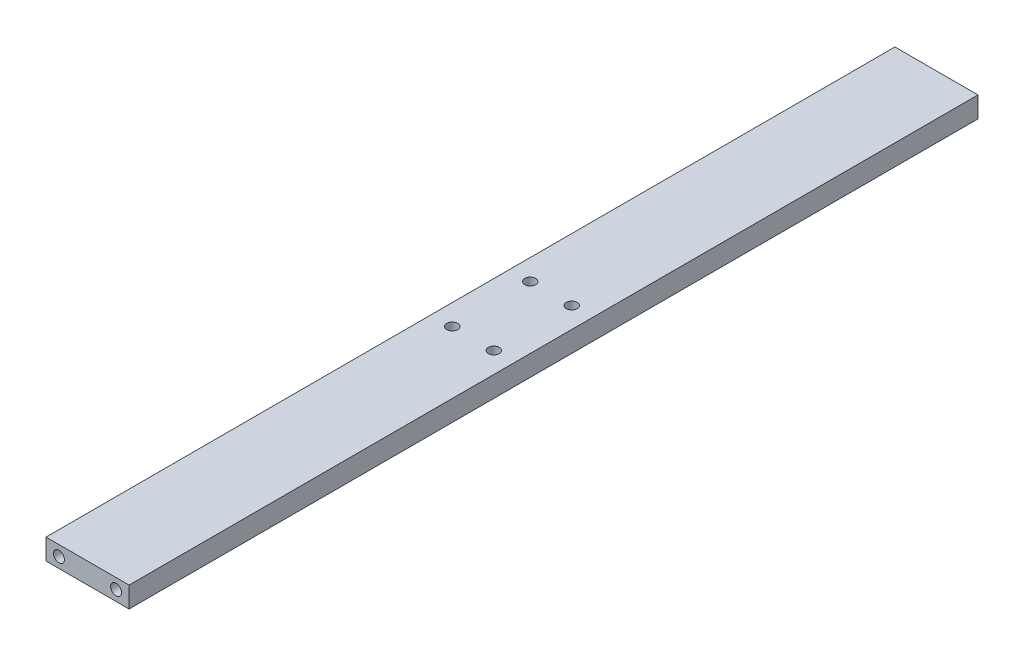
from build123d import *

# Parameters (mm, degrees)
SKETCH1_W           = 32
SKETCH1_H           = 8
BOSS_EXTRUDE1_DEPTH = 163.5
SKETCH2_R           = 2.1
CUT_EXTRUDE1_DEPTH  = 10
CUT_EXTRUDE2_REACH  = 10
SKETCH3_R           = 2.1


with BuildPart() as part:
    # Sketch1 → Boss-Extrude1 (new body, symmetric)
    with BuildSketch(Plane.XY):
        Rectangle(SKETCH1_W, SKETCH1_H)
    extrude(amount=BOSS_EXTRUDE1_DEPTH, both=True)

    # Sketch2 → Cut-Extrude1 (cut)
    with BuildSketch(Plane.XY.offset(163.5)):
        with Locations((11, 0)):
            Circle(SKETCH2_R)
        with Locations((-11, 0)):
            Circle(SKETCH2_R)
    cut_extrude1 = extrude(amount=-CUT_EXTRUDE1_DEPTH, mode=Mode.SUBTRACT)

    # Mirror1: Cut-Extrude1 across plane
    add(cut_extrude1.mirror(Plane.XY), mode=Mode.SUBTRACT)

    # Sketch3 → Cut-Extrude2 (cut, up to next)
    with BuildSketch(Plane(origin=(0, 4, 0), x_dir=(1, 0, 0), z_dir=(0, 1, 0)), mode=Mode.PRIVATE) as cut_extrude2_sk1:
        with Locations((-8, -15)):
            Circle(SKETCH3_R)
    cut_extrude2_tool1 = extrude(cut_extrude2_sk1.sketch, amount=-CUT_EXTRUDE2_REACH, mode=Mode.PRIVATE) & part.part
    add(cut_extrude2_tool1.solids().sort_by_distance((-8, 4, 15))[0], mode=Mode.SUBTRACT)
    # Sketch3 → Cut-Extrude2 (cut, up to next)
    with BuildSketch(Plane(origin=(0, 4, 0), x_dir=(1, 0, 0), z_dir=(0, 1, 0)), mode=Mode.PRIVATE) as cut_extrude2_sk2:
        with Locations((-8, 15)):
            Circle(SKETCH3_R)
    cut_extrude2_tool2 = extrude(cut_extrude2_sk2.sketch, amount=-CUT_EXTRUDE2_REACH, mode=Mode.PRIVATE) & part.part
    add(cut_extrude2_tool2.solids().sort_by_distance((-8, 4, -15))[0], mode=Mode.SUBTRACT)
    # Sketch3 → Cut-Extrude2 (cut, up to next)
    with BuildSketch(Plane(origin=(0, 4, 0), x_dir=(1, 0, 0), z_dir=(0, 1, 0)), mode=Mode.PRIVATE) as cut_extrude2_sk3:
        with Locations((8, -15)):
            Circle(SKETCH3_R)
    cut_extrude2_tool3 = extrude(cut_extrude2_sk3.sketch, amount=-CUT_EXTRUDE2_REACH, mode=Mode.PRIVATE) & part.part
    add(cut_extrude2_tool3.solids().sort_by_distance((8, 4, 15))[0], mode=Mode.SUBTRACT)
    # Sketch3 → Cut-Extrude2 (cut, up to next)
    with BuildSketch(Plane(origin=(0, 4, 0), x_dir=(1, 0, 0), z_dir=(0, 1, 0)), mode=Mode.PRIVATE) as cut_extrude2_sk4:
        with Locations((8, 15)):
            Circle(SKETCH3_R)
    cut_extrude2_tool4 = extrude(cut_extrude2_sk4.sketch, amount=-CUT_EXTRUDE2_REACH, mode=Mode.PRIVATE) & part.part
    add(cut_extrude2_tool4.solids().sort_by_distance((8, 4, -15))[0], mode=Mode.SUBTRACT)


solid = part.part
